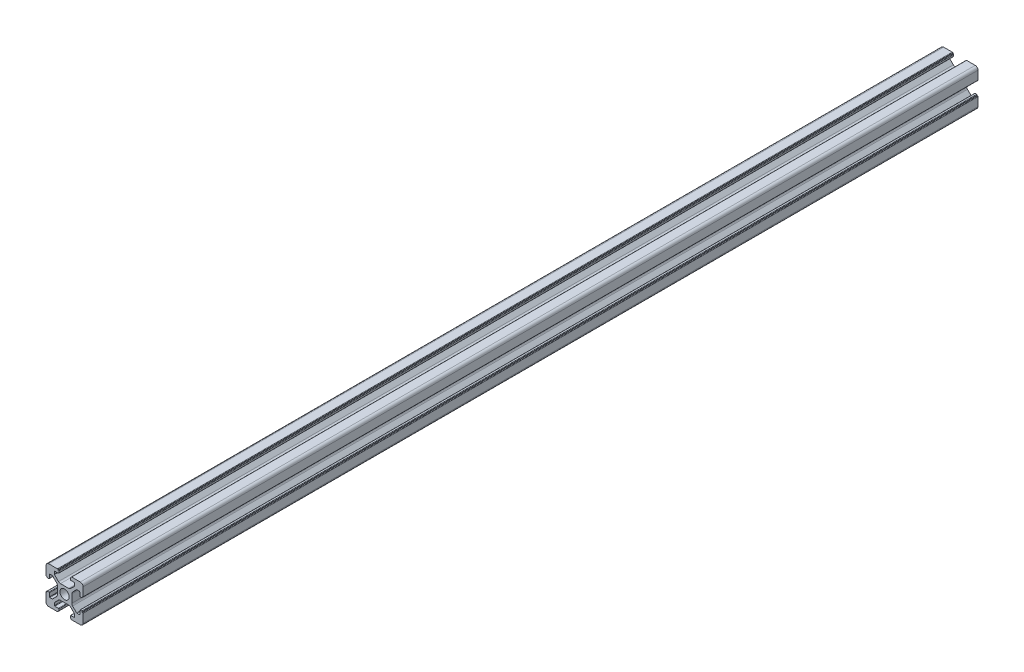
from build123d import *

# Parameters (mm, degrees)
SKETCH_1_R      = 2.5
EXTRUDE_1_DEPTH = 482.6


with BuildPart() as part:
    # 草图1 → 凸台-拉伸1 (new body)
    with BuildSketch(Plane.XY):
        with BuildLine():
            Line((-8.502261885, -10.002261885), (-3.85, -10.002261885))
            ThreePointArc((-3.85, -10.002261885), (-3.673223305, -9.929038581), (-3.6, -9.752261885))
            Line((-3.6, -9.752261885), (-3.6, -9.502261885))
            Line((-3.6, -9.502261885), (-3.35, -9.502261885))
            ThreePointArc((-3.35, -9.502261885), (-3.173223305, -9.429038581), (-3.1, -9.252261885))
            Line((-3.1, -9.252261885), (-3.1, -8.45))
            ThreePointArc((-3.1, -8.45), (-3.173223305, -8.273223305), (-3.35, -8.2))
            Line((-3.35, -8.2), (-5.25, -8.2))
            ThreePointArc((-5.25, -8.2), (-5.426776695, -8.126776695), (-5.5, -7.95))
            Line((-5.5, -7.95), (-5.5, -6.664213562))
            ThreePointArc((-5.5, -6.664213562), (-5.480969883, -6.568542704), (-5.426776695, -6.487436867))
            Line((-5.426776695, -6.487436867), (-3.278679656, -4.339339828))
            ThreePointArc((-3.278679656, -4.339339828), (-2.792044633, -4.014180701), (-2.218019485, -3.9))
            Line((-2.218019485, -3.9), (2.218019485, -3.9))
            ThreePointArc((2.218019485, -3.9), (2.792044633, -4.014180701), (3.278679656, -4.339339828))
            Line((3.278679656, -4.339339828), (5.426776695, -6.487436867))
            ThreePointArc((5.426776695, -6.487436867), (5.480969883, -6.568542704), (5.5, -6.664213562))
            Line((5.5, -6.664213562), (5.5, -7.95))
            ThreePointArc((5.5, -7.95), (5.426776695, -8.126776695), (5.25, -8.2))
            Line((5.25, -8.2), (3.35, -8.2))
            ThreePointArc((3.35, -8.2), (3.173223305, -8.273223305), (3.1, -8.45))
            Line((3.1, -8.45), (3.1, -9.252261885))
            ThreePointArc((3.1, -9.252261885), (3.173223305, -9.429038581), (3.35, -9.502261885))
            Line((3.35, -9.502261885), (3.6, -9.502261885))
            Line((3.6, -9.502261885), (3.6, -9.752261885))
            ThreePointArc((3.6, -9.752261885), (3.673223305, -9.929038581), (3.85, -10.002261885))
            Line((3.85, -10.002261885), (8.502261885, -10.002261885))
            ThreePointArc((8.502261885, -10.002261885), (9.562922057, -9.562922057), (10.002261885, -8.502261885))
            Line((10.002261885, -8.502261885), (10.002261885, -3.85))
            ThreePointArc((10.002261885, -3.85), (9.929038581, -3.673223305), (9.752261885, -3.6))
            Line((9.752261885, -3.6), (9.502261885, -3.6))
            Line((9.502261885, -3.6), (9.502261885, -3.35))
            ThreePointArc((9.502261885, -3.35), (9.429038581, -3.173223305), (9.252261885, -3.1))
            Line((9.252261885, -3.1), (8.45, -3.1))
            ThreePointArc((8.45, -3.1), (8.273223305, -3.173223305), (8.2, -3.35))
            Line((8.2, -3.35), (8.2, -5.25))
            ThreePointArc((8.2, -5.25), (8.126776695, -5.426776695), (7.95, -5.5))
            Line((7.95, -5.5), (6.664213562, -5.5))
            ThreePointArc((6.664213562, -5.5), (6.568542704, -5.480969883), (6.487436867, -5.426776695))
            Line((6.487436867, -5.426776695), (4.339339828, -3.278679656))
            ThreePointArc((4.339339828, -3.278679656), (4.014180701, -2.792044633), (3.9, -2.218019485))
            Line((3.9, -2.218019485), (3.9, 2.218019485))
            ThreePointArc((3.9, 2.218019485), (4.014180701, 2.792044633), (4.339339828, 3.278679656))
            Line((4.339339828, 3.278679656), (6.487436867, 5.426776695))
            ThreePointArc((6.487436867, 5.426776695), (6.568542704, 5.480969883), (6.664213562, 5.5))
            Line((6.664213562, 5.5), (7.95, 5.5))
            ThreePointArc((7.95, 5.5), (8.126776695, 5.426776695), (8.2, 5.25))
            Line((8.2, 5.25), (8.2, 3.35))
            ThreePointArc((8.2, 3.35), (8.273223305, 3.173223305), (8.45, 3.1))
            Line((8.45, 3.1), (9.252261885, 3.1))
            ThreePointArc((9.252261885, 3.1), (9.429038581, 3.173223305), (9.502261885, 3.35))
            Line((9.502261885, 3.35), (9.502261885, 3.6))
            Line((9.502261885, 3.6), (9.752261885, 3.6))
            ThreePointArc((9.752261885, 3.6), (9.929038581, 3.673223305), (10.002261885, 3.85))
            Line((10.002261885, 3.85), (10.002261885, 8.502261885))
            ThreePointArc((10.002261885, 8.502261885), (9.562922057, 9.562922057), (8.502261885, 10.002261885))
            Line((8.502261885, 10.002261885), (3.85, 10.002261885))
            ThreePointArc((3.85, 10.002261885), (3.673223305, 9.929038581), (3.6, 9.752261885))
            Line((3.6, 9.752261885), (3.6, 9.502261885))
            Line((3.6, 9.502261885), (3.35, 9.502261885))
            ThreePointArc((3.35, 9.502261885), (3.173223305, 9.429038581), (3.1, 9.252261885))
            Line((3.1, 9.252261885), (3.1, 8.45))
            ThreePointArc((3.1, 8.45), (3.173223305, 8.273223305), (3.35, 8.2))
            Line((3.35, 8.2), (5.25, 8.2))
            ThreePointArc((5.25, 8.2), (5.426776695, 8.126776695), (5.5, 7.95))
            Line((5.5, 7.95), (5.5, 6.664213562))
            ThreePointArc((5.5, 6.664213562), (5.480969883, 6.568542704), (5.426776695, 6.487436867))
            Line((5.426776695, 6.487436867), (3.278679656, 4.339339828))
            ThreePointArc((3.278679656, 4.339339828), (2.792044633, 4.014180701), (2.218019485, 3.9))
            Line((2.218019485, 3.9), (-2.218019485, 3.9))
            ThreePointArc((-2.218019485, 3.9), (-2.792044633, 4.014180701), (-3.278679656, 4.339339828))
            Line((-3.278679656, 4.339339828), (-5.426776695, 6.487436867))
            ThreePointArc((-5.426776695, 6.487436867), (-5.480969883, 6.568542704), (-5.5, 6.664213562))
            Line((-5.5, 6.664213562), (-5.5, 7.95))
            ThreePointArc((-5.5, 7.95), (-5.426776695, 8.126776695), (-5.25, 8.2))
            Line((-5.25, 8.2), (-3.35, 8.2))
            ThreePointArc((-3.35, 8.2), (-3.173223305, 8.273223305), (-3.1, 8.45))
            Line((-3.1, 8.45), (-3.1, 9.252261885))
            ThreePointArc((-3.1, 9.252261885), (-3.173223305, 9.429038581), (-3.35, 9.502261885))
            Line((-3.35, 9.502261885), (-3.6, 9.502261885))
            Line((-3.6, 9.502261885), (-3.6, 9.752261885))
            ThreePointArc((-3.6, 9.752261885), (-3.673223305, 9.929038581), (-3.85, 10.002261885))
            Line((-3.85, 10.002261885), (-8.502261885, 10.002261885))
            ThreePointArc((-8.502261885, 10.002261885), (-9.562922057, 9.562922057), (-10.002261885, 8.502261885))
            Line((-10.002261885, 8.502261885), (-10.002261885, 3.85))
            ThreePointArc((-10.002261885, 3.85), (-9.929038581, 3.673223305), (-9.752261885, 3.6))
            Line((-9.752261885, 3.6), (-9.502261885, 3.6))
            Line((-9.502261885, 3.6), (-9.502261885, 3.35))
            ThreePointArc((-9.502261885, 3.35), (-9.429038581, 3.173223305), (-9.252261885, 3.1))
            Line((-9.252261885, 3.1), (-8.45, 3.1))
            ThreePointArc((-8.45, 3.1), (-8.273223305, 3.173223305), (-8.2, 3.35))
            Line((-8.2, 3.35), (-8.2, 5.25))
            ThreePointArc((-8.2, 5.25), (-8.126776695, 5.426776695), (-7.95, 5.5))
            Line((-7.95, 5.5), (-6.664213562, 5.5))
            ThreePointArc((-6.664213562, 5.5), (-6.568542704, 5.480969883), (-6.487436867, 5.426776695))
            Line((-6.487436867, 5.426776695), (-4.339339828, 3.278679656))
            ThreePointArc((-4.339339828, 3.278679656), (-4.014180701, 2.792044633), (-3.9, 2.218019485))
            Line((-3.9, 2.218019485), (-3.9, -2.218019485))
            ThreePointArc((-3.9, -2.218019485), (-4.014180701, -2.792044633), (-4.339339828, -3.278679656))
            Line((-4.339339828, -3.278679656), (-6.487436867, -5.426776695))
            ThreePointArc((-6.487436867, -5.426776695), (-6.568542704, -5.480969883), (-6.664213562, -5.5))
            Line((-6.664213562, -5.5), (-7.95, -5.5))
            ThreePointArc((-7.95, -5.5), (-8.126776695, -5.426776695), (-8.2, -5.25))
            Line((-8.2, -5.25), (-8.2, -3.35))
            ThreePointArc((-8.2, -3.35), (-8.273223305, -3.173223305), (-8.45, -3.1))
            Line((-8.45, -3.1), (-9.252261885, -3.1))
            ThreePointArc((-9.252261885, -3.1), (-9.429038581, -3.173223305), (-9.502261885, -3.35))
            Line((-9.502261885, -3.35), (-9.502261885, -3.6))
            Line((-9.502261885, -3.6), (-9.752261885, -3.6))
            ThreePointArc((-9.752261885, -3.6), (-9.929038581, -3.673223305), (-10.002261885, -3.85))
            Line((-10.002261885, -3.85), (-10.002261885, -8.502261885))
            ThreePointArc((-10.002261885, -8.502261885), (-9.562922057, -9.562922057), (-8.502261885, -10.002261885))
        make_face()
        Circle(SKETCH_1_R, mode=Mode.SUBTRACT)
    extrude(amount=EXTRUDE_1_DEPTH)


solid = part.part
